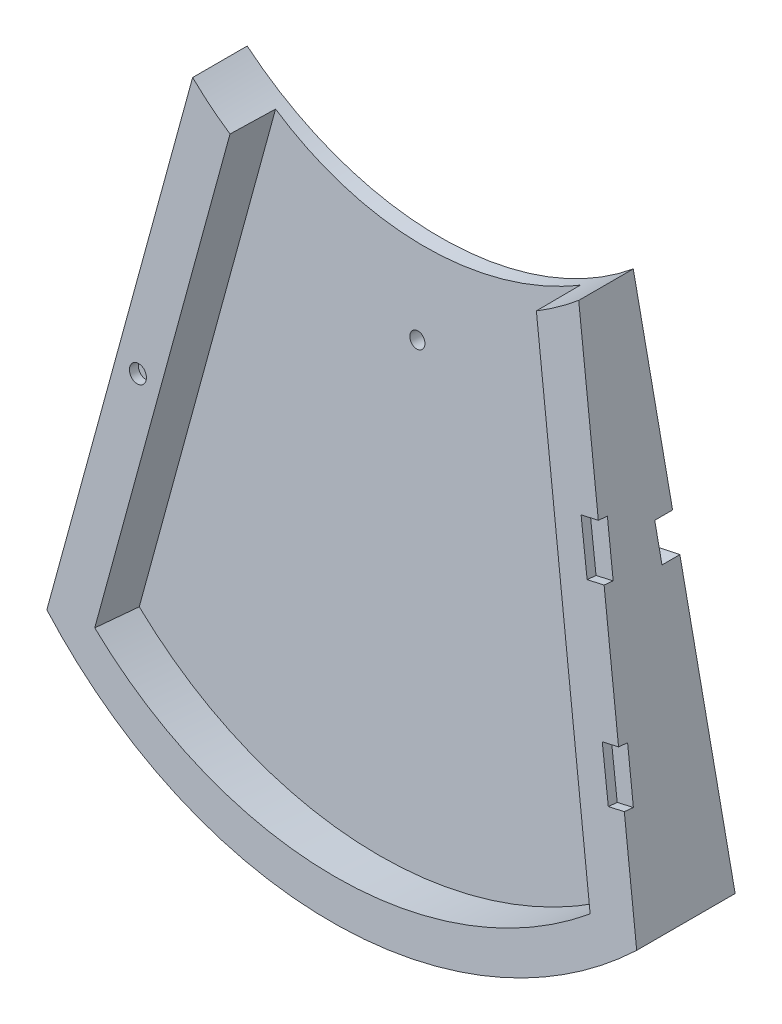
from build123d import *

# Parameters (mm, degrees)
BOSS_EXTRUDE1_DEPTH     = 209.55
SKETCH1_W               = 240.510539239
SKETCH1_H               = 265.827438106
CUT_EXTRUDE1_DEPTH      = 41.01815501
CUT_EXTRUDE1_DEPTH_BACK = 1
CUT_EXTRUDE2_DEPTH      = 15.875
CUT_EXTRUDE3_DEPTH      = 3.175
SKETCH5_R               = 3
CUT_EXTRUDE4_DEPTH      = 3.175
CUT_EXTRUDE7_DEPTH      = 3.175
CUT_EXTRUDE7_DEPTH_BACK = 6.35
SKETCH7_R               = 2.667
CUT_EXTRUDE8_DEPTH      = 23.690934342
CUT_EXTRUDE9_DEPTH      = 6.35


with BuildPart() as part:
    # Sketch2 → Boss-Extrude1 (new body)
    with BuildSketch(Plane(origin=(0, 0, 0), x_dir=(0, 0, -1), z_dir=(1, 0, 0))):
        Polygon((-19.05, 177.8), (-34.91779298, 0.709477538), (-40.01815501, -56.212476111), (0, -53.790492508), (0, 0), (0, 177.8), align=None)
    extrude(amount=BOSS_EXTRUDE1_DEPTH)

    # Sketch1 → Cut-Extrude1 (cut, two sides)
    with BuildSketch(Plane.XY) as cut_extrude1_sk:
        with Locations((107.411926899, 58.758625739)):
            Rectangle(SKETCH1_W, SKETCH1_H)
        with BuildLine():
            Line((0, 0), (36.195, 174.07688524))
            ThreePointArc((36.195, 174.07688524), (104.775, 149.493461876), (173.355, 174.07688524))
            Line((173.355, 174.07688524), (209.55, 0))
            ThreePointArc((209.55, 0), (104.775, -41.729500882), (0, 0))
        make_face(mode=Mode.SUBTRACT)
    extrude(amount=CUT_EXTRUDE1_DEPTH, mode=Mode.SUBTRACT)
    extrude(cut_extrude1_sk.sketch, amount=-CUT_EXTRUDE1_DEPTH_BACK, mode=Mode.SUBTRACT)

    # Sketch3 → Cut-Extrude2 (cut)
    with BuildSketch(Plane(origin=(0, 3.474785103, 34.670013893), x_dir=(1, 0, 0), z_dir=(0, 0.08924518, 0.996009688))):
        with BuildLine():
            Line((92.029425275, 362.610535175), (16.77359238, -0.776250458))
            ThreePointArc((16.77359238, -0.776250458), (104.775, -31.999740282), (192.77640762, -0.776250458))
            Line((192.77640762, -0.776250458), (117.520574725, 362.610535175))
            Line((117.520574725, 362.610535175), (92.029425275, 362.610535175))
        make_face()
    extrude(amount=-CUT_EXTRUDE2_DEPTH, mode=Mode.SUBTRACT)

    # Sketch4 → Cut-Extrude3 (cut)
    with BuildSketch(Plane(origin=(0, 3.109460703, 34.702747954), x_dir=(1, 0, 0), z_dir=(0, 0.08924518, 0.996009688))):
        Polygon((185.970172739, 112.605103669), (179.585708922, 111.245651158), (183.288614458, 93.855513419), (189.673078275, 95.21496593), align=None)
        Polygon((198.756641777, 51.702635333), (192.545878299, 50.380169071), (196.248783835, 32.990031331), (202.459547313, 34.312497594), align=None)
    extrude(amount=-CUT_EXTRUDE3_DEPTH, mode=Mode.SUBTRACT)

    # Sketch5 → Cut-Extrude4 (cut)
    with BuildSketch(Plane(origin=(0, 3.109460703, 34.702747954), x_dir=(1, 0, 0), z_dir=(0, 0.08924518, 0.996009688))):
        with Locations(Location((25.057058463, 78.729771517, 0), (0, 0, 270))):  # turned: the seam where the file's is
            Circle(SKETCH5_R)
    extrude(amount=-CUT_EXTRUDE4_DEPTH, mode=Mode.SUBTRACT)

    # Sketch6 → Cut-Extrude7 (cut, two sides)
    with BuildSketch(Plane(origin=(0, 0, 0), x_dir=(-1, 0, 0), z_dir=(0, 0, -1))) as cut_extrude7_sk:
        with BuildLine():
            Line((-203.2, -5.683612864), (-203.2, 0.666387136))
            ThreePointArc((-203.2, 0.666387136), (-104.775, -36.938393832), (-6.35, 0.666387136))
            Line((-6.35, 0.666387136), (-6.35, -5.683612864))
            ThreePointArc((-6.35, -5.683612864), (-104.775, -63.961814377), (-203.2, -5.683612864))
        make_face()
    extrude(amount=CUT_EXTRUDE7_DEPTH, mode=Mode.SUBTRACT)
    extrude(cut_extrude7_sk.sketch, amount=-CUT_EXTRUDE7_DEPTH_BACK, mode=Mode.SUBTRACT)

    # Sketch7 → Cut-Extrude8 (cut, through all)
    with BuildSketch(Plane(origin=(0, 1.692693472, 18.891094163), x_dir=(1, 0, 0), z_dir=(0, 0.08924518, 0.996009688))):
        with Locations(Location((104.775, 120.767047718, 0), (0, 0, 270))):  # turned: the seam where the file's is
            Circle(SKETCH7_R)
    extrude(amount=-CUT_EXTRUDE8_DEPTH, mode=Mode.SUBTRACT)

    # Sketch8 → Cut-Extrude9 (cut)
    with BuildSketch(Plane(origin=(0, 0, 0), x_dir=(-1, 0, 0), z_dir=(0, 0, -1))):
        Polygon((-187.325, 106.889315498), (-189.910357143, 94.455252267), (-179.341403396, 92.257698696), (-176.756046253, 104.691761927), align=None)
        Polygon((-32.793953747, 104.691761927), (-22.225, 106.889315498), (-19.639642857, 94.455252267), (-30.208596604, 92.257698696), align=None)
    extrude(amount=-CUT_EXTRUDE9_DEPTH, mode=Mode.SUBTRACT)


solid = part.part
